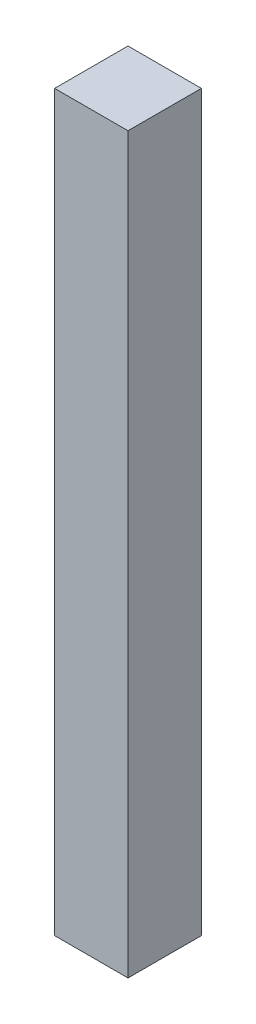
from build123d import *

# Parameters (mm, degrees)
SKETCH_1_W      = 120
SKETCH_1_H      = 120
EXTRUDE_1_DEPTH = 1200


with BuildPart() as part:
    # Эскиз1 → Бобышка-Вытянуть1 (new body)
    with BuildSketch(Plane(origin=(0, 0, 0), x_dir=(1, 0, 0), z_dir=(0, 1, 0))):
        with Locations((60, 60)):
            Rectangle(SKETCH_1_W, SKETCH_1_H)
    extrude(amount=EXTRUDE_1_DEPTH)


solid = part.part
